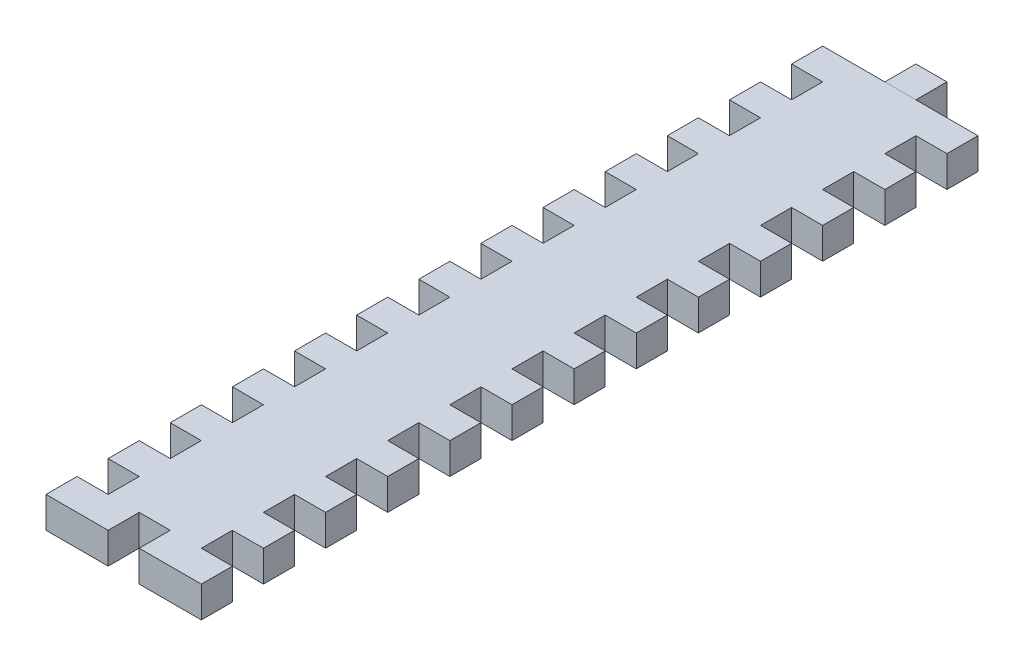
from build123d import *

# Parameters (mm, degrees)
BOSS_EXTRUDE1_DEPTH = 4
SKETCH2_W           = 4
SKETCH2_H           = 4
BOSS_EXTRUDE2_DEPTH = 4
SKETCH3_W           = 4
SKETCH3_H           = 4
CUT_EXTRUDE1_DEPTH  = 10


with BuildPart() as part:
    # Sketch1 → Boss-Extrude1 (new body)
    with BuildSketch(Plane(origin=(0, 0, 0), x_dir=(1, 0, 0), z_dir=(0, 1, 0))):
        Polygon((0, 30.166666667), (-4, 30.166666667), (-4, 26.166666667), (0, 26.166666667), (0, 22.166666667), (-4, 22.166666667), (-4, 18.166666667), (0, 18.166666667), (0, 14.166666667), (-4, 14.166666667), (-4, 10.166666667), (0, 10.166666667), (0, 6.166666667), (-4, 6.166666667), (-4, 2.166666667), (0, 2.166666667), (0, -1.833333333), (-4, -1.833333333), (-4, -5.833333333), (0, -5.833333333), (0, -9.833333333), (-4, -9.833333333), (-4, -13.833333333), (0, -13.833333333), (0, -17.833333333), (-4, -17.833333333), (-4, -21.833333333), (0, -21.833333333), (0, -25.833333333), (-4, -25.833333333), (-4, -29.833333333), (0, -29.833333333), (0, -33.833333333), (-4, -33.833333333), (-4, -37.833333333), (0, -37.833333333), (0, -41.833333333), (-4, -41.833333333), (-4, -45.833333333), (0, -45.833333333), (0, -49.833333333), (-4, -49.833333333), (-4, -53.833333333), (0, -53.833333333), (0, -57.833333333), (-4, -57.833333333), (-4, -61.833333333), (0, -61.833333333), (0, -65.833333333), (-4, -65.833333333), (-4, -69.833333333), (16, -69.833333333), (16, -65.833333333), (12, -65.833333333), (12, -61.833333333), (16, -61.833333333), (16, -57.833333333), (12, -57.833333333), (12, -53.833333333), (16, -53.833333333), (16, -49.833333333), (12, -49.833333333), (12, -45.833333333), (16, -45.833333333), (16, -41.833333333), (12, -41.833333333), (12, -37.833333333), (16, -37.833333333), (16, -33.833333333), (12, -33.833333333), (12, -29.833333333), (16, -29.833333333), (16, -25.833333333), (12, -25.833333333), (12, -21.833333333), (16, -21.833333333), (16, -17.833333333), (12, -17.833333333), (12, -13.833333333), (16, -13.833333333), (16, -9.833333333), (12, -9.833333333), (12, -5.833333333), (16, -5.833333333), (16, -1.833333333), (12, -1.833333333), (12, 2.166666667), (16, 2.166666667), (16, 6.166666667), (12, 6.166666667), (12, 10.166666667), (16, 10.166666667), (16, 14.166666667), (12, 14.166666667), (12, 18.166666667), (16, 18.166666667), (16, 22.166666667), (12, 22.166666667), (12, 26.166666667), (16, 26.166666667), (16, 30.166666667), (12, 30.166666667), align=None)
    extrude(amount=BOSS_EXTRUDE1_DEPTH)

    # Sketch3 → Cut-Extrude1 (cut)
    with BuildSketch(Plane(origin=(0, 4, 0), x_dir=(1, 0, 0), z_dir=(0, 1, 0))):
        with Locations((6, -67.833333333)):
            Rectangle(SKETCH3_W, SKETCH3_H)
    extrude(amount=-CUT_EXTRUDE1_DEPTH, mode=Mode.SUBTRACT)


with BuildPart() as body_2:
    # Sketch2 → Boss-Extrude2 (new body)
    with BuildSketch(Plane(origin=(0, 4, 0), x_dir=(1, 0, 0), z_dir=(0, 1, 0))):
        with Locations((6, 32.166666667)):
            Rectangle(SKETCH2_W, SKETCH2_H)
    extrude(amount=-BOSS_EXTRUDE2_DEPTH)


solid = Compound([part.part, body_2.part])
